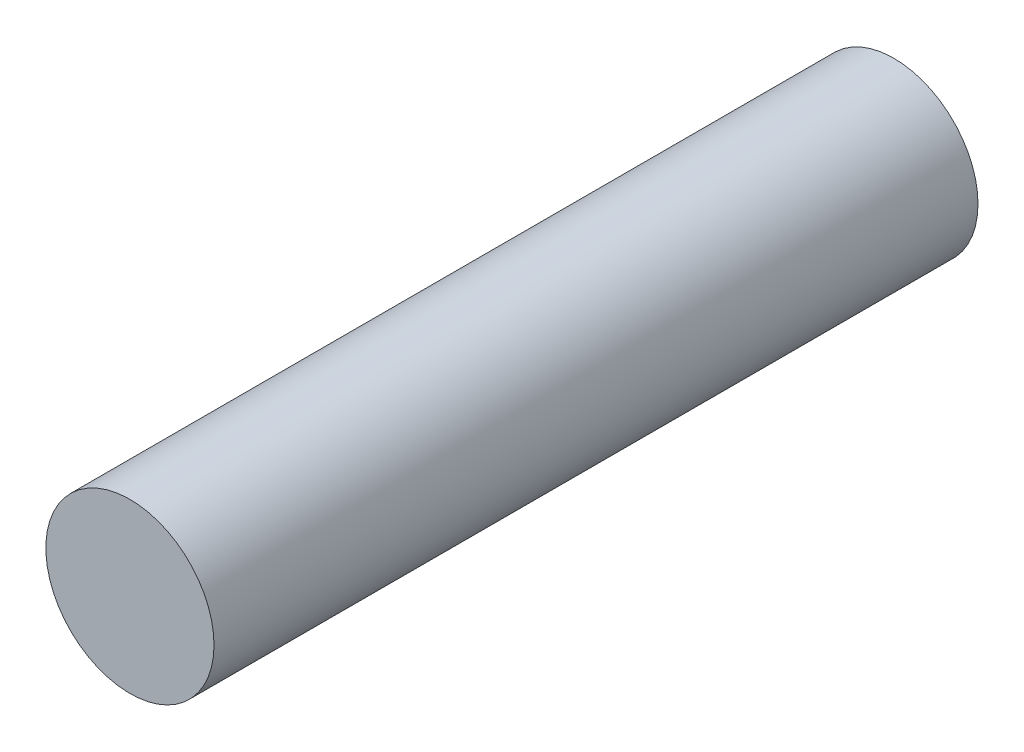
from build123d import *

# Parameters (mm, degrees)
SKETCH1_R           = 16.51
BOSS_EXTRUDE1_DEPTH = 150


with BuildPart() as part:
    # Sketch1 → Boss-Extrude1 (new body)
    with BuildSketch(Plane.XY):
        Circle(SKETCH1_R)
    extrude(amount=BOSS_EXTRUDE1_DEPTH)


solid = part.part
